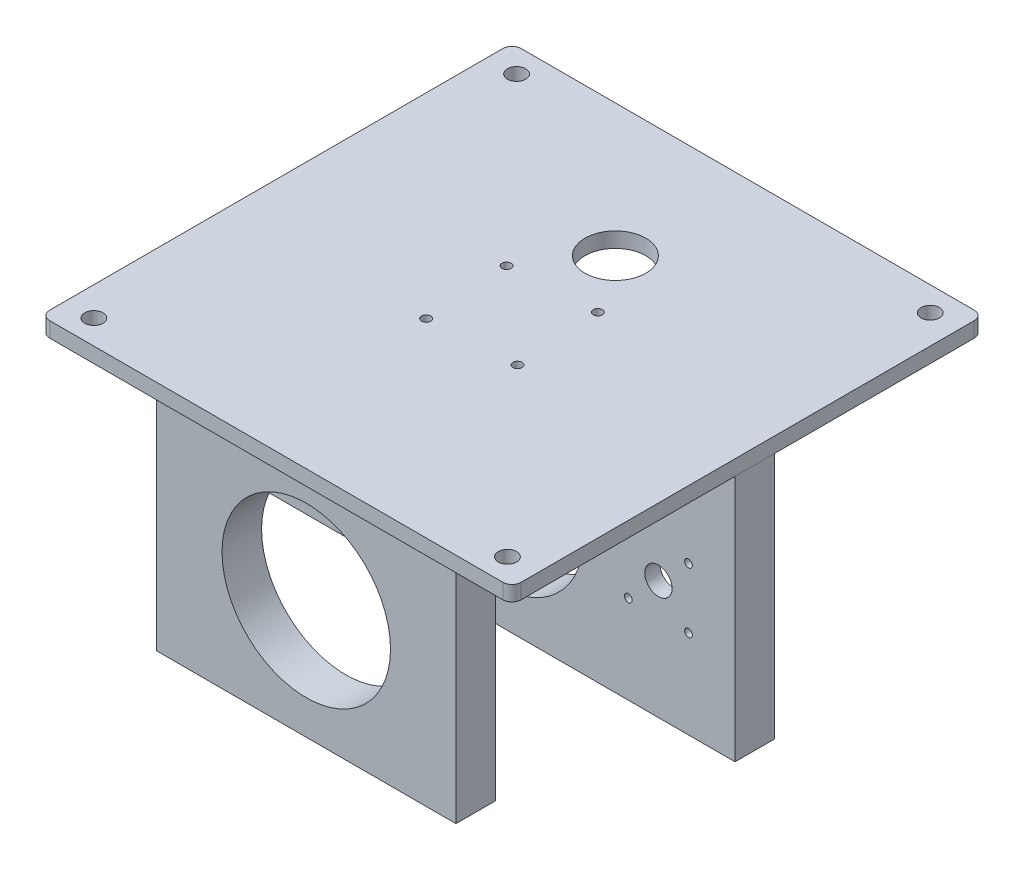
from build123d import *

# Parameters (mm, degrees)
SKETCH1_R           = 10
SKETCH1_R_2         = 3
SKETCH1_R_3         = 1.5
BOSS_EXTRUDE1_DEPTH = 5
SKETCH2_W           = 98.431457506
SKETCH2_H           = 81.46271096
SKETCH2_R           = 27.7
BOSS_EXTRUDE2_DEPTH = 13
SKETCH3_W           = 155
SKETCH3_H           = 81.46271096
SKETCH3_R           = 27.7
SKETCH3_R_2         = 1.2645
SKETCH3_R_3         = 4.5
BOSS_EXTRUDE3_DEPTH = 13
CUT_EXTRUDE1_START  = -5
SKETCH4_R           = 18.5
SKETCH4_R_2         = 4.5
SKETCH4_R_3         = 1.2645
CUT_EXTRUDE1_DEPTH  = 5
CUT_EXTRUDE2_START  = -8
SKETCH4_3_R         = 11
SKETCH4_3_R_2       = 4.5
CUT_EXTRUDE2_DEPTH  = 8
LPATTERN1_COUNT     = 2
LPATTERN1_PITCH     = 104.6
CUT_EXTRUDE3_START  = -36
SKETCH5_W           = 23.598249953
SKETCH5_H           = 5
CUT_EXTRUDE3_DEPTH  = 23


with BuildPart() as part:
    # Sketch1 → Boss-Extrude1 (new body)
    with BuildSketch(Plane(origin=(0, 0, 0), x_dir=(1, 0, 0), z_dir=(0, 1, 0))):
        with BuildLine():
            Line((74.653701946, 78.479138322), (-74.346298054, 78.479138322))
            ThreePointArc((-74.346298054, 78.479138322), (-76.467618398, 77.600458666), (-77.346298054, 75.479138322))
            Line((-77.346298054, 75.479138322), (-77.346298054, -73.520861678))
            ThreePointArc((-77.346298054, -73.520861678), (-76.467618398, -75.642182022), (-74.346298054, -76.520861678))
            Line((-74.346298054, -76.520861678), (74.653701946, -76.520861678))
            ThreePointArc((74.653701946, -76.520861678), (76.775022289, -75.642182022), (77.653701946, -73.520861678))
            Line((77.653701946, -73.520861678), (77.653701946, 75.479138322))
            ThreePointArc((77.653701946, 75.479138322), (76.775022289, 77.600458666), (74.653701946, 78.479138322))
        make_face()
        with Locations((0.153701946, 34.979138322)):
            Circle(SKETCH1_R, mode=Mode.SUBTRACT)
        with Locations((68.153701946, -68.520861678)):
            Circle(SKETCH1_R_2, mode=Mode.SUBTRACT)
        with Locations((68.153701946, 70.479138322)):
            Circle(SKETCH1_R_2, mode=Mode.SUBTRACT)
        with Locations((-67.846298054, 70.479138322)):
            Circle(SKETCH1_R_2, mode=Mode.SUBTRACT)
        with Locations((-67.846298054, -68.520861678)):
            Circle(SKETCH1_R_2, mode=Mode.SUBTRACT)
        with Locations((-14.862359946, 14.189660085)):
            Circle(SKETCH1_R_3, mode=Mode.SUBTRACT)
        with Locations((-13.056819817, -14.03692357)):
            Circle(SKETCH1_R_3, mode=Mode.SUBTRACT)
        with Locations((15.169763838, -12.231383441)):
            Circle(SKETCH1_R_3, mode=Mode.SUBTRACT)
        with Locations((13.364223709, 15.995200214)):
            Circle(SKETCH1_R_3, mode=Mode.SUBTRACT)
    extrude(amount=-BOSS_EXTRUDE1_DEPTH)

    # Sketch2 → Boss-Extrude2 (add)
    with BuildSketch(Plane.XY.offset(66.520861678)):
        with Locations((0, -45.73135548)):
            Rectangle(SKETCH2_W, SKETCH2_H)
        with Locations((0, -47.5)):
            Circle(SKETCH2_R, mode=Mode.SUBTRACT)
    extrude(amount=-BOSS_EXTRUDE2_DEPTH)

    # Sketch3 → Boss-Extrude3 (add)
    with BuildSketch(Plane(origin=(0, 0, 3.020861678), x_dir=(-1, 0, 0), z_dir=(0, 0, -1))):
        with Locations((0, -45.73135548)):
            Rectangle(SKETCH3_W, SKETCH3_H)
        with Locations((0, -47.5)):
            Circle(SKETCH3_R, mode=Mode.SUBTRACT)
        with Locations((42.400505063, -57.399494937)):
            Circle(SKETCH3_R_2, mode=Mode.SUBTRACT)
        with Locations((42.400505063, -37.600505063)):
            Circle(SKETCH3_R_2, mode=Mode.SUBTRACT)
        with Locations((52.3, -47.5)):
            Circle(SKETCH3_R_3, mode=Mode.SUBTRACT)
        with Locations((62.199494937, -37.600505063)):
            Circle(SKETCH3_R_2, mode=Mode.SUBTRACT)
        with Locations((62.199494937, -57.399494937)):
            Circle(SKETCH3_R_2, mode=Mode.SUBTRACT)
        with Locations((-42.400505063, -57.390997892)):
            Circle(SKETCH3_R_2, mode=Mode.SUBTRACT)
        with Locations((-42.400505063, -37.592008019)):
            Circle(SKETCH3_R_2, mode=Mode.SUBTRACT)
        with Locations((-52.3, -47.5)):
            Circle(SKETCH3_R_3, mode=Mode.SUBTRACT)
        with Locations((-62.199494937, -57.390997892)):
            Circle(SKETCH3_R_2, mode=Mode.SUBTRACT)
        with Locations((-62.199494937, -37.592008019)):
            Circle(SKETCH3_R_2, mode=Mode.SUBTRACT)
    extrude(amount=BOSS_EXTRUDE3_DEPTH)

    # Sketch4 → Cut-Extrude1 (cut)
    with BuildSketch(Plane(origin=(0, 0, -9.979138322), x_dir=(-1, 0, 0), z_dir=(0, 0, -1)).offset(CUT_EXTRUDE1_START)):
        with Locations((52.3, -47.5)):
            Circle(SKETCH4_R)
        with Locations((52.3, -47.5)):
            Circle(SKETCH4_R_2, mode=Mode.SUBTRACT)
        with Locations((42.400505063, -57.399494937)):
            Circle(SKETCH4_R_3, mode=Mode.SUBTRACT)
        with Locations((62.199494937, -57.399494937)):
            Circle(SKETCH4_R_3, mode=Mode.SUBTRACT)
        with Locations((42.400505063, -37.600505063)):
            Circle(SKETCH4_R_3, mode=Mode.SUBTRACT)
        with Locations((62.199494937, -37.600505063)):
            Circle(SKETCH4_R_3, mode=Mode.SUBTRACT)
    cut_extrude1 = extrude(amount=CUT_EXTRUDE1_DEPTH, mode=Mode.SUBTRACT)

    # Sketch4_3 → Cut-Extrude2 (cut)
    with BuildSketch(Plane(origin=(0, 0, -9.979138322), x_dir=(-1, 0, 0), z_dir=(0, 0, -1)).offset(CUT_EXTRUDE2_START)):
        with Locations((52.3, -47.5)):
            Circle(SKETCH4_3_R)
        with Locations((52.3, -47.5)):
            Circle(SKETCH4_3_R_2, mode=Mode.SUBTRACT)
    cut_extrude2 = extrude(amount=CUT_EXTRUDE2_DEPTH, mode=Mode.SUBTRACT)

    # LPattern1: Cut-Extrude1, Cut-Extrude2 ×2
    with Locations(*[(i * LPATTERN1_PITCH, 0, 0) for i in range(1, LPATTERN1_COUNT)]):
        add(cut_extrude1, mode=Mode.SUBTRACT)
        add(cut_extrude2, mode=Mode.SUBTRACT)

    # Sketch5 → Cut-Extrude3 (cut)
    with BuildSketch(Plane(origin=(0, 0, 0), x_dir=(1, 0, 0), z_dir=(0, 1, 0)).offset(CUT_EXTRUDE3_START)):
        with Locations((52.291592137, 7.479138322)):
            Rectangle(SKETCH5_W, SKETCH5_H)
    extrude(amount=-CUT_EXTRUDE3_DEPTH, mode=Mode.SUBTRACT)


solid = part.part
